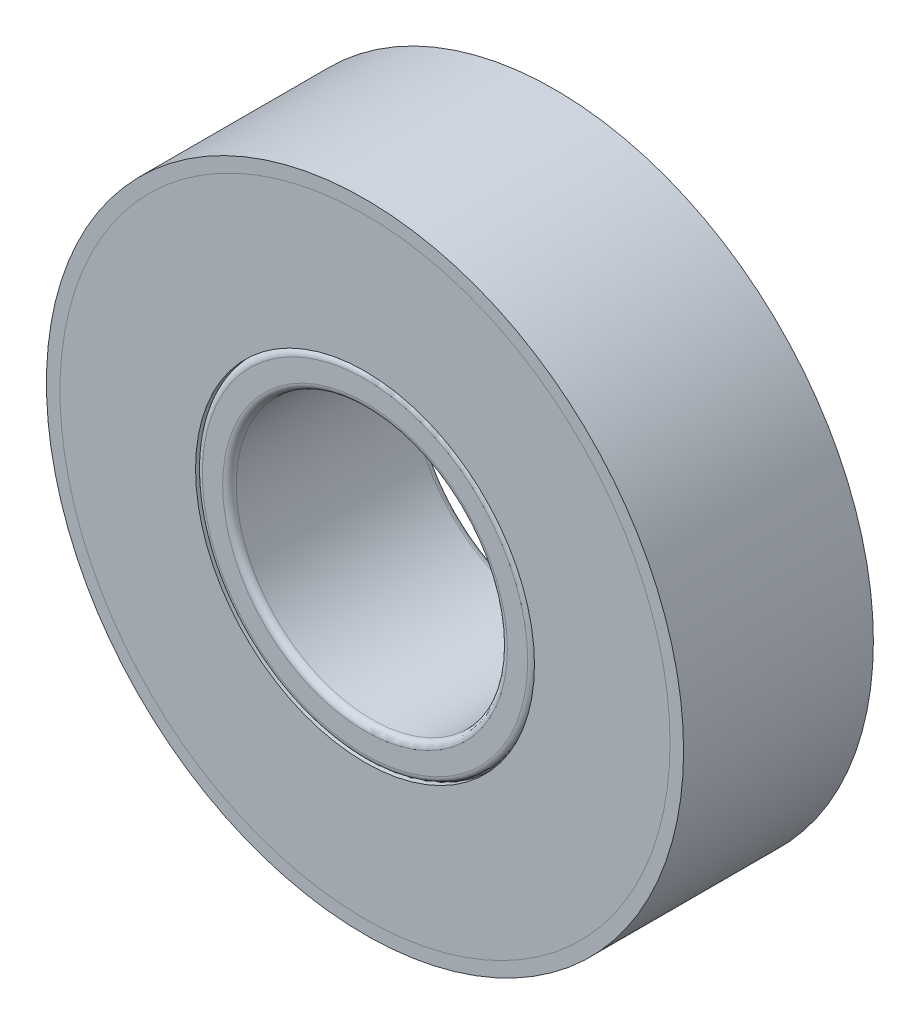
from build123d import *

# Parameters (mm, degrees)
SKETCH1_R               = 23.5
SKETCH1_R_2             = 10
BOSS_EXTRUDE1_DEPTH     = 14
SKETCH2_R               = 22.5
SKETCH2_R_2             = 12.5
CUT_EXTRUDE1_DEPTH      = 14
CIRCULAR_PATTERN1_COUNT = 10
FILLET1_R               = 0.5
FILLET3_R               = 0.5
SKETCH5_R               = 22.5
SKETCH5_R_2             = 12.5
BOSS_EXTRUDE3_DEPTH     = 0.5
SKETCH6_R               = 22.5
SKETCH6_R_2             = 12.5
BOSS_EXTRUDE4_DEPTH     = 0.5
FILLET5_R               = 0.5
FILLET6_R               = 0.5


with BuildPart() as part:
    # Sketch1 → Boss-Extrude1 (new body)
    with BuildSketch(Plane.XY):
        Circle(SKETCH1_R)
        Circle(SKETCH1_R_2, mode=Mode.SUBTRACT)
    extrude(amount=BOSS_EXTRUDE1_DEPTH)

    # Sketch2 → Cut-Extrude1 (cut)
    with BuildSketch(Plane.XY.offset(14)):
        Circle(SKETCH2_R)
        Circle(SKETCH2_R_2, mode=Mode.SUBTRACT)
    extrude(amount=-CUT_EXTRUDE1_DEPTH, mode=Mode.SUBTRACT)

    # Sketch3 → Revolve1 (revolve)
    with BuildSketch(Plane(origin=(0, 0, 0), x_dir=(0, 0, -1), z_dir=(1, 0, 0))):
        with BuildLine():
            Line((-6.822615032, 22.5), (-6.822615032, 12.493708894))
            ThreePointArc((-6.822615032, 12.493708894), (-1.819469479, 17.496854447), (-6.822615032, 22.5))
        make_face()
    revolve1 = revolve(axis=Axis((0, 22.5, 6.822615032), (0, -1, 0)))

    # Circular-Pattern1: Revolve1 ×10 about axis
    circular_pattern1_axis = Axis((0, 0, 0), (0, 0, 1))
    for i in range(1, CIRCULAR_PATTERN1_COUNT):
        add(revolve1.rotate(circular_pattern1_axis, i * 360 / CIRCULAR_PATTERN1_COUNT))

    # Fillet1
    fillet1_edges = [part.edges().sort_by_distance(p)[0] for p in [
        (-10, 0, 0),
    ]]
    fillet(fillet1_edges, radius=FILLET1_R)

    # Fillet3
    fillet3_edges = [part.edges().sort_by_distance(p)[0] for p in [
        (-12.5, 0, 0),
    ]]
    fillet(fillet3_edges, radius=FILLET3_R)

    # Fillet5
    fillet5_edges = [part.edges().sort_by_distance(p)[0] for p in [
        (-12.5, 0, 14),
    ]]
    fillet(fillet5_edges, radius=FILLET5_R)

    # Fillet6
    fillet6_edges = [part.edges().sort_by_distance(p)[0] for p in [
        (-10, 0, 14),
    ]]
    fillet(fillet6_edges, radius=FILLET6_R)


with BuildPart() as body_2:
    # Sketch5 → Boss-Extrude3 (new body)
    with BuildSketch(Plane.XY):
        Circle(SKETCH5_R)
        Circle(SKETCH5_R_2, mode=Mode.SUBTRACT)
    extrude(amount=BOSS_EXTRUDE3_DEPTH)


with BuildPart() as body_3:
    # Sketch6 → Boss-Extrude4 (new body)
    with BuildSketch(Plane.XY.offset(14)):
        Circle(SKETCH6_R)
        Circle(SKETCH6_R_2, mode=Mode.SUBTRACT)
    extrude(amount=-BOSS_EXTRUDE4_DEPTH)


solid = Compound([part.part, body_2.part, body_3.part])
